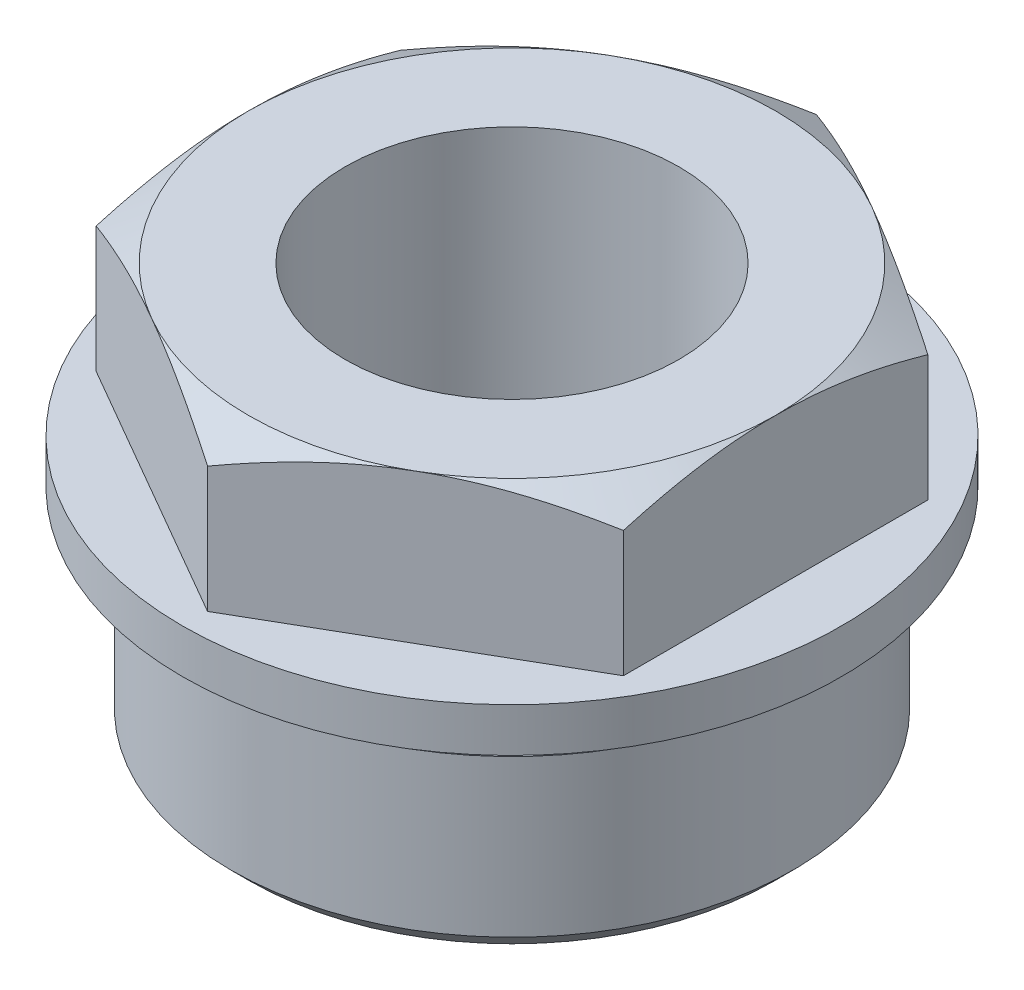
from build123d import *

# Parameters (mm, degrees)
CHAMFER_1_SIZE      = 2.195
SKETCH_2_R          = 37.5
CUT_EXTRUDE_1_DEPTH = 18
SKETCH_3_R          = 25
EXTRUDE_1_DEPTH     = 17


with BuildPart() as part:
    # Эскиз1 → Повернуть1 (revolve)
    with BuildSketch(Plane.XY):
        Polygon((25, 0), (32, 0), (32, 20), (28, 20), (28, 24), (37.5, 24), (37.5, 29), (32.5, 29), (32.5, 42.535898385), (26.5, 46), (19, 46), (19, 5), (25, 5), align=None)
    revolve(axis=Axis((0, 57.260780425, 0), (0, -1, 0)))

    # Фаска1
    chamfer_1_edges = [part.edges().sort_by_distance(p)[0] for p in [
        (-32, 0, 0),
    ]]
    chamfer(chamfer_1_edges, length=CHAMFER_1_SIZE)

    # Эскиз2 → Вырез-Вытянуть1 (cut, through all)
    with BuildSketch(Plane(origin=(0, 29, 0), x_dir=(1, 0, 0), z_dir=(0, 1, 0))):
        Circle(SKETCH_2_R)
        Polygon((0, 34.641016151), (-30, 17.320508076), (-30, -17.320508076), (0, -34.641016151), (30, -17.320508076), (30, 17.320508076), align=None, mode=Mode.SUBTRACT)
    extrude(amount=CUT_EXTRUDE_1_DEPTH, mode=Mode.SUBTRACT)

    # Эскиз3 → Бобышка-Вытянуть1 (add)
    with BuildSketch(Plane(origin=(0, 29, 0), x_dir=(1, 0, 0), z_dir=(0, 1, 0))):
        Polygon((0, 34.641016151), (-30, 17.320508076), (-30, -17.320508076), (0, -34.641016151), (30, -17.320508076), (30, 17.320508076), align=None)
        Circle(SKETCH_3_R, mode=Mode.SUBTRACT)
    extrude(amount=EXTRUDE_1_DEPTH)

    # Эскиз4 → Вырез-Повернуть1 (revolve, cut)
    with BuildSketch(Plane.XY):
        Polygon((-30, 46), (-45, 46), (-45, 37.339745962), align=None)
    revolve(axis=Axis((0, 0, 0), (0, 1, 0)), mode=Mode.SUBTRACT)


solid = part.part
